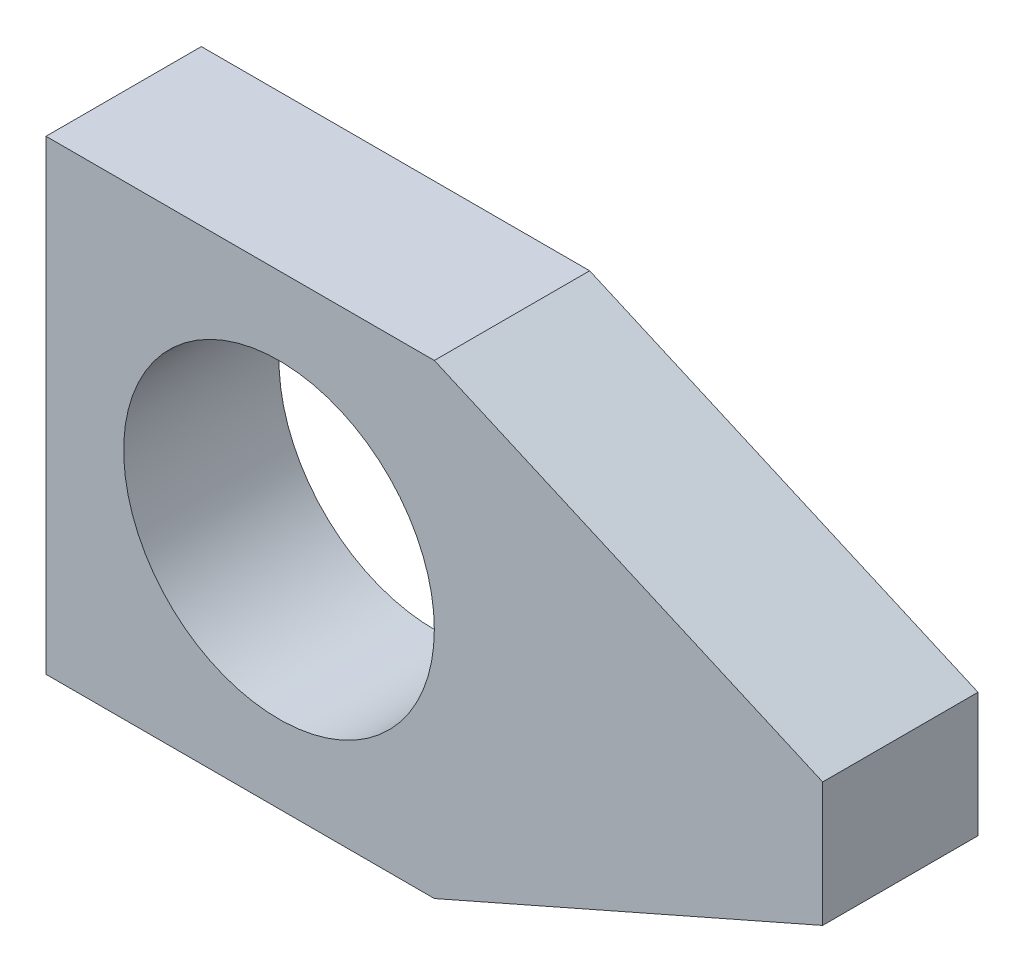
from build123d import *

# Parameters (mm, degrees)
SKETCH1_R           = 10
BOSS_EXTRUDE1_DEPTH = 10


with BuildPart() as part:
    # Sketch1 → Boss-Extrude1 (new body)
    with BuildSketch(Plane.XY):
        Polygon((-15, 15), (10, 15), (35, 4), (35, -4), (10, -15), (-15, -15), align=None)
        Circle(SKETCH1_R, mode=Mode.SUBTRACT)
    extrude(amount=BOSS_EXTRUDE1_DEPTH)


solid = part.part
